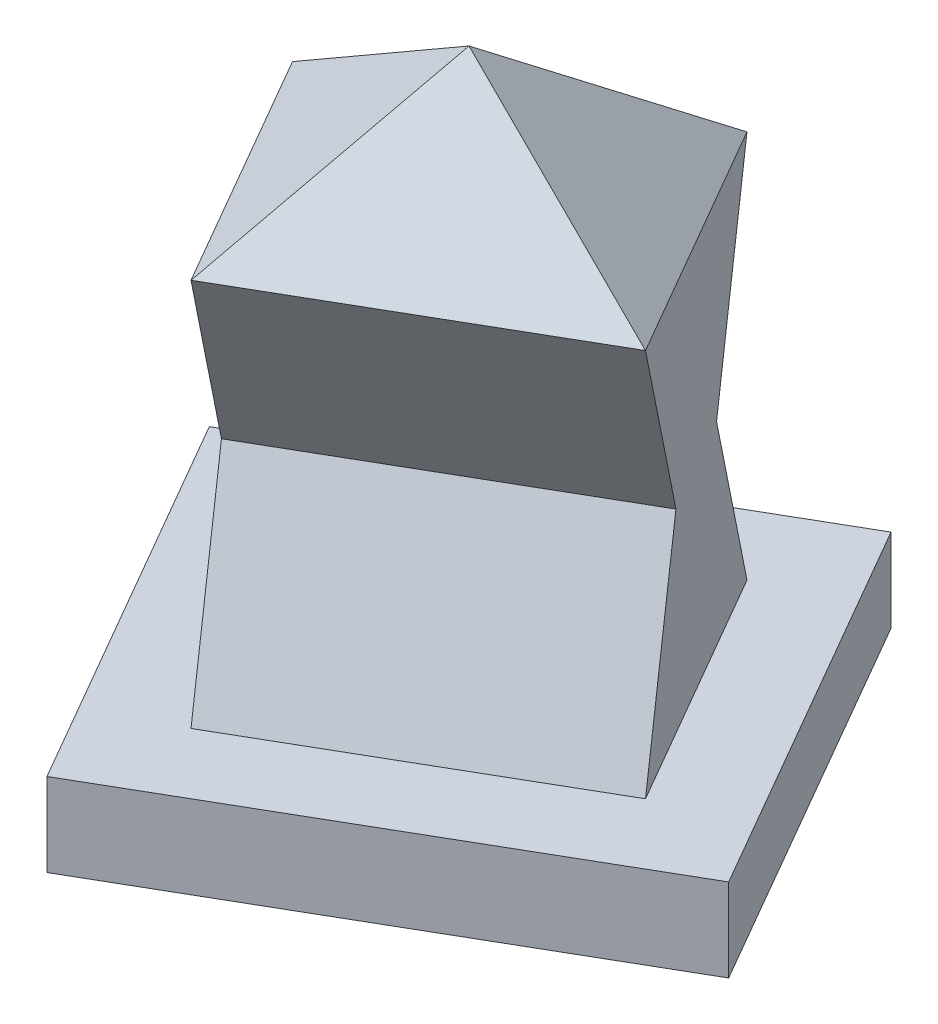
from build123d import *

# Parameters (mm, degrees)
EXTRUDE1_DEPTH     = 15
EXTRUDE2_DEPTH     = 70
CUT_EXTRUDE1_DEPTH = 60


with BuildPart() as part:
    # Sketch1 → Extrude1 (new body)
    with BuildSketch(Plane(origin=(0, 0, 0), x_dir=(1, 0, 0), z_dir=(0, 1, 0))):
        Polygon((-58.97114317, 12.141016151), (18.97114317, 57.141016151), (58.97114317, -12.141016151), (-18.97114317, -57.141016151), align=None)
    extrude(amount=EXTRUDE1_DEPTH)

    # Sketch2 → Extrude2 (add)
    with BuildSketch(Plane(origin=(0, 15, 0), x_dir=(-1, 0, 0), z_dir=(0, 1, 0))):
        Polygon((38.480762114, -6.650635095), (-13.480762114, -36.650635095), (-38.480762114, 6.650635095), (13.480762114, 36.650635095), align=None)
    extrude(amount=EXTRUDE2_DEPTH)

    # Sketch3 → Cut-Extrude1 (cut)
    with BuildSketch(Plane(origin=(-25.980762114, 0, 15), x_dir=(0.5, 0, 0.866025404), z_dir=(-0.866025404, 0, 0.5))):
        Polygon((-25, 15), (-25, 85), (-10, 50), align=None)
        Polygon((25, 85), (25, 15), (10, 50), align=None)
    extrude(amount=-CUT_EXTRUDE1_DEPTH, mode=Mode.SUBTRACT)

    # Sketch4 → Loft1 section 0
    with BuildSketch(Plane(origin=(0, 85, 0), x_dir=(-1, 0, 0), z_dir=(0, 1, 0)), mode=Mode.PRIVATE) as loft1_s0:
        Polygon((38.480762114, -6.650635095), (-13.480762114, -36.650635095), (-38.480762114, 6.650635095), (13.480762114, 36.650635095), align=None)
    loft([loft1_s0.sketch, Vertex(0, 110, 0)])


solid = part.part
